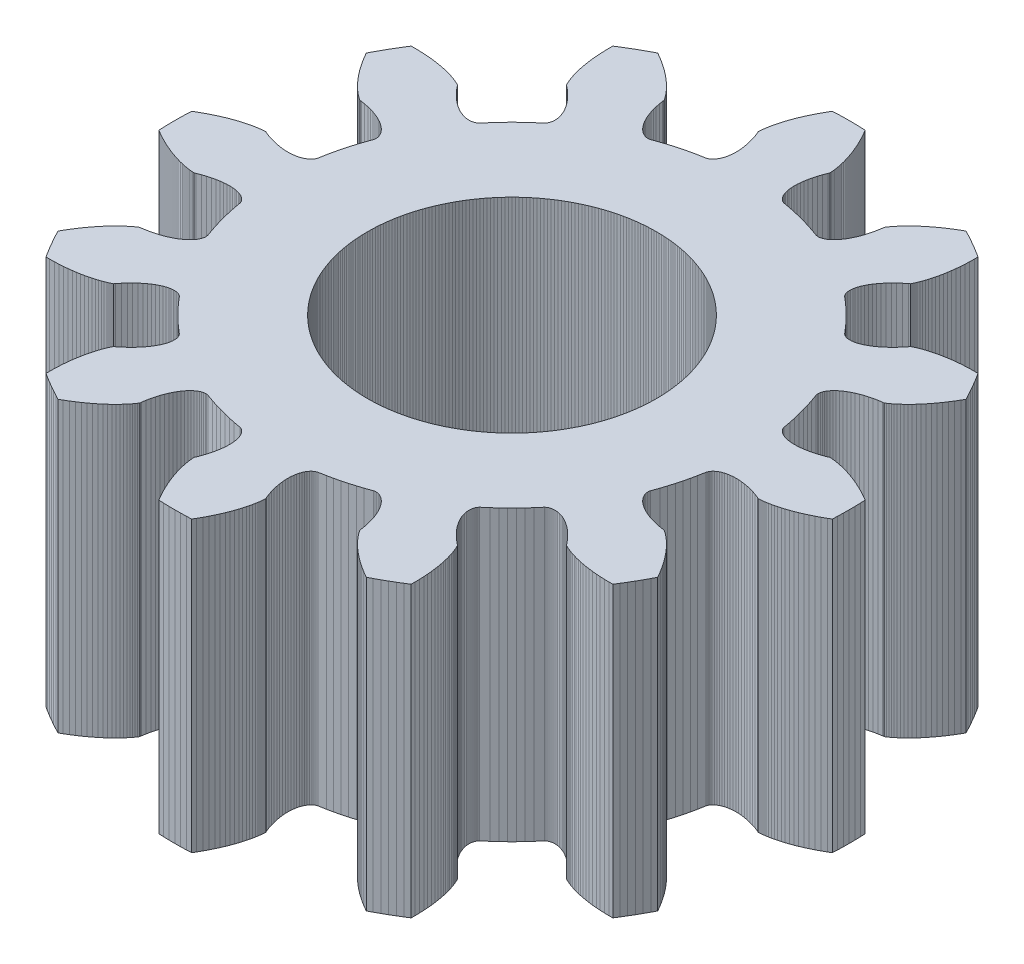
from build123d import *

# Parameters (mm, degrees)
BOSS_EXTRUDE1_DEPTH = 6.35


with BuildPart() as part:
    # Sketch3 → Boss-Extrude1 (new body)
    with BuildSketch(Plane(origin=(0, 0, 0), x_dir=(1, 0, 0), z_dir=(0, 1, 0))):
        Polygon((6.352324032, -3.811995371), (6.415800573, -3.704164188), (6.477446846, -3.5952763), (6.537245267, -3.48536277), (6.588458816, -3.387319635), (6.548537306, -3.316595297), (6.495884299, -3.228769109), (6.443215338, -3.145914469), (6.390753066, -3.06796958), (6.338716813, -2.994864435), (6.287322326, -2.926520952), (6.236781496, -2.862853119), (6.187302087, -2.803767138), (6.139087482, -2.749161584), (6.092336423, -2.698927578), (6.047242762, -2.652948955), (6.003995218, -2.611102449), (5.962777138, -2.573257887), (5.92376627, -2.53927838), (5.887134532, -2.509020536), (5.853047802, -2.482334667), (5.821665703, -2.459065011), (5.793141399, -2.439049957), (5.767621407, -2.422122279), (5.760449484, -2.417630883), (5.727783615, -2.415600485), (5.636581741, -2.400512835), (5.550113125, -2.382418476), (5.468469721, -2.361555299), (5.391734266, -2.338163872), (5.319980198, -2.312487121), (5.253271597, -2.284770003), (5.191663125, -2.255259188), (5.13519999, -2.224202732), (5.083917906, -2.191849747), (5.037843073, -2.158450081), (4.996992084, -2.124254211), (4.961372336, -2.08951179), (4.930981205, -2.054473591), (4.905806921, -2.019388861), (4.885828153, -1.984506202), (4.871014126, -1.950073026), (4.861324716, -1.916335146), (4.856710476, -1.883536522), (4.857112722, -1.851918927), (4.862463612, -1.821721631), (4.91656345, -1.668948402), (4.958566642, -1.539675868), (4.997171481, -1.409348117), (5.032351508, -1.278054469), (5.064082612, -1.145884906), (5.092343047, -1.012930011), (5.121877828, -0.853574595), (5.13234247, -0.824747525), (5.147802912, -0.797164761), (5.168198273, -0.771067439), (5.193458489, -0.746694283), (5.2235044, -0.724281291), (5.258247849, -0.704061425), (5.297591783, -0.686264298), (5.341430376, -0.671115876), (5.389649152, -0.658838167), (5.442125122, -0.649648933), (5.498726931, -0.643761391), (5.559315011, -0.641383926), (5.623741749, -0.642719814), (5.691851657, -0.647966934), (5.76348156, -0.657317507), (5.838460781, -0.670957821), (5.916611348, -0.689067979), (5.997748198, -0.71182164), (6.081679396, -0.739385773), (6.16820636, -0.771920423), (6.197511031, -0.78649498), (6.205967799, -0.786191279), (6.236532595, -0.784291448), (6.271243328, -0.781220033), (6.31005542, -0.776759019), (6.352918329, -0.770691743), (6.399771266, -0.76280355), (6.450545422, -0.752881869), (6.505163607, -0.740716556), (6.563540332, -0.726100191), (6.6255819, -0.708828366), (6.691186508, -0.68869997), (6.760244357, -0.665517476), (6.832637773, -0.639087219), (6.908241333, -0.609219674), (6.986922005, -0.575729725), (7.068539294, -0.538436939), (7.1529454, -0.497165821), (7.239985377, -0.451746078), (7.329497313, -0.402012872), (7.399432523, -0.360724553), (7.404101857, -0.250209934), (7.407271671, -0.125122814), (7.408328376, 0), (7.407271671, 0.125122814), (7.404101857, 0.250209934), (7.399432523, 0.360724553), (7.329497313, 0.402012872), (7.239985377, 0.451746078), (7.1529454, 0.497165821), (7.068539294, 0.538436939), (6.986922005, 0.575729725), (6.908241333, 0.609219674), (6.832637773, 0.639087219), (6.760244357, 0.665517476), (6.691186508, 0.68869997), (6.6255819, 0.708828366), (6.563540332, 0.726100191), (6.505163607, 0.740716556), (6.450545422, 0.752881869), (6.399771266, 0.76280355), (6.352918329, 0.770691743), (6.31005542, 0.776759019), (6.271242896, 0.781220082), (6.236532598, 0.784291476), (6.205967798, 0.786191279), (6.197511031, 0.78649498), (6.16820636, 0.771920423), (6.081679396, 0.739385773), (5.997748198, 0.71182164), (5.916611348, 0.689067979), (5.838460781, 0.670957821), (5.76348156, 0.657317507), (5.691851657, 0.647966934), (5.623741749, 0.642719814), (5.559315011, 0.641383926), (5.498726931, 0.64376139), (5.442125122, 0.649648933), (5.389649193, 0.658837931), (5.341430376, 0.671115876), (5.297591785, 0.686264282), (5.25824785, 0.704061406), (5.2235044, 0.724281291), (5.193458489, 0.746694283), (5.168198273, 0.771067439), (5.147802912, 0.797164761), (5.13234247, 0.824747525), (5.121877828, 0.853574595), (5.092343048, 1.012930011), (5.064082612, 1.145884906), (5.032351508, 1.278054469), (4.997171481, 1.409348117), (4.958566642, 1.539675868), (4.916563449, 1.668948402), (4.862463612, 1.821721631), (4.857112722, 1.851918927), (4.856710476, 1.883536522), (4.861324716, 1.916335146), (4.871014126, 1.950073026), (4.885828153, 1.984506202), (4.905806929, 2.019388845), (4.930981212, 2.054473575), (4.961372336, 2.08951179), (4.996992167, 2.124253986), (5.037843073, 2.158450081), (5.083917906, 2.191849747), (5.13519999, 2.224202732), (5.191663125, 2.255259188), (5.253271597, 2.284770003), (5.319980198, 2.312487121), (5.391734266, 2.338163872), (5.468469721, 2.361555299), (5.550113125, 2.382418476), (5.636581741, 2.400512835), (5.727783615, 2.415600485), (5.760449483, 2.417630883), (5.767621408, 2.42212228), (5.793141383, 2.43904998), (5.821666052, 2.45906527), (5.853047802, 2.482334667), (5.887134532, 2.509020536), (5.92376627, 2.53927838), (5.962777138, 2.573257887), (6.003995218, 2.611102449), (6.047242762, 2.652948955), (6.092336423, 2.698927578), (6.139087482, 2.749161584), (6.187302087, 2.803767138), (6.236781496, 2.862853119), (6.287322326, 2.926520952), (6.338716813, 2.994864435), (6.390753066, 3.06796958), (6.443215338, 3.145914469), (6.495884299, 3.228769109), (6.548537306, 3.316595297), (6.588458816, 3.387319635), (6.537245267, 3.48536277), (6.477446846, 3.5952763), (6.415800573, 3.704164188), (6.352324032, 3.811995371), (6.287035334, 3.918739087), (6.227734262, 4.012112889), (6.146524434, 4.012902016), (6.044138221, 4.011216269), (5.946049518, 4.00703093), (5.852316127, 4.000569714), (5.762987088, 3.99205757), (5.678102653, 3.98172038), (5.597694277, 3.969784654), (5.521784611, 3.95647722), (5.450387512, 3.942024924), (5.383508057, 3.926654322), (5.321142571, 3.910591377), (5.263278662, 3.894061158), (5.20989527, 3.877287535), (5.160962719, 3.860492886), (5.116442789, 3.843897793), (5.076288783, 3.827720753), (5.04044562, 3.812177885), (5.008849923, 3.797482641), (4.981430128, 3.783845519), (4.973954503, 3.779880148), (4.955863193, 3.752605876), (4.897195968, 3.681166561), (4.838291485, 3.615329722), (4.779401742, 3.555056049), (4.720776444, 3.500296909), (4.662662691, 3.450994439), (4.605304663, 3.407081654), (4.548943312, 3.36848256), (4.493816064, 3.335112279), (4.440156515, 3.306877183), (4.38819414, 3.283675041), (4.338154153, 3.265394982), (4.29025646, 3.251918585), (4.244716924, 3.243118194), (4.201745515, 3.238858989), (4.161546862, 3.238998198), (4.124319843, 3.243385462), (4.090257276, 3.251863127), (4.059545715, 3.26426639), (4.032365197, 3.280423543), (4.008889017, 3.300156197), (3.903633438, 3.423394646), (3.812681736, 3.524406745), (3.719117012, 3.623003391), (3.623003391, 3.719117012), (3.524406745, 3.812681736), (3.423394645, 3.903633438), (3.300156197, 4.008889017), (3.280423543, 4.032365197), (3.26426639, 4.059545715), (3.251863127, 4.090257276), (3.243385462, 4.124319843), (3.238998198, 4.161546862), (3.238859004, 4.201745504), (3.243118208, 4.244716913), (3.251918585, 4.29025646), (3.265395166, 4.338153999), (3.283675041, 4.38819414), (3.306877184, 4.440156515), (3.335112279, 4.493816064), (3.36848256, 4.548943312), (3.407081654, 4.605304663), (3.450994439, 4.662662691), (3.500296909, 4.720776444), (3.555056049, 4.779401742), (3.615329722, 4.838291485), (3.681166561, 4.897195968), (3.752605876, 4.955863193), (3.779880148, 4.973954503), (3.783845519, 4.981430129), (3.797482616, 5.008849935), (3.812178058, 5.040446019), (3.827720753, 5.076288783), (3.843897793, 5.116442789), (3.860492886, 5.160962719), (3.877287535, 5.20989527), (3.894061158, 5.263278662), (3.910591377, 5.321142571), (3.926654322, 5.383508057), (3.942024924, 5.450387512), (3.95647722, 5.521784611), (3.969784654, 5.597694277), (3.98172038, 5.678102653), (3.99205757, 5.762987088), (4.000569714, 5.852316127), (4.00703093, 5.946049518), (4.011216269, 6.044138221), (4.012902016, 6.146524434), (4.012112889, 6.227734262), (3.918739087, 6.287035334), (3.811995371, 6.352324032), (3.704164188, 6.415800573), (3.5952763, 6.477446846), (3.48536277, 6.537245267), (3.387319635, 6.588458816), (3.316595297, 6.548537306), (3.228769109, 6.495884299), (3.145914469, 6.443215338), (3.06796958, 6.390753066), (2.994864435, 6.338716813), (2.926520952, 6.287322326), (2.862853119, 6.236781496), (2.803767138, 6.187302087), (2.749161584, 6.139087482), (2.698927578, 6.092336423), (2.652948955, 6.047242762), (2.611102449, 6.003995218), (2.573257887, 5.962777138), (2.53927838, 5.92376627), (2.509020536, 5.887134532), (2.482334667, 5.853047802), (2.459065011, 5.821665703), (2.439049957, 5.793141399), (2.422122279, 5.767621407), (2.417630883, 5.760449484), (2.415600485, 5.727783615), (2.400512835, 5.636581741), (2.382418476, 5.550113125), (2.361555299, 5.468469721), (2.338163872, 5.391734266), (2.312487121, 5.319980198), (2.284770003, 5.253271597), (2.255259188, 5.191663125), (2.224202732, 5.13519999), (2.191849747, 5.083917906), (2.158450081, 5.037843073), (2.124254211, 4.996992084), (2.08951179, 4.961372336), (2.054473591, 4.930981205), (2.019388861, 4.905806921), (1.984506202, 4.885828153), (1.950073026, 4.871014126), (1.916335146, 4.861324716), (1.883536522, 4.856710476), (1.851918927, 4.857112722), (1.821721631, 4.862463612), (1.668948402, 4.91656345), (1.539675868, 4.958566642), (1.409348117, 4.997171481), (1.278054469, 5.032351508), (1.145884906, 5.064082612), (1.012930011, 5.092343047), (0.853574595, 5.121877828), (0.824747525, 5.13234247), (0.797164761, 5.147802912), (0.771067439, 5.168198273), (0.746694283, 5.193458489), (0.724281291, 5.2235044), (0.704061425, 5.258247849), (0.686264298, 5.297591783), (0.671115876, 5.341430376), (0.658838167, 5.389649152), (0.649648933, 5.442125122), (0.643761391, 5.498726931), (0.641383926, 5.559315011), (0.642719814, 5.623741749), (0.647966934, 5.691851657), (0.657317507, 5.76348156), (0.670957821, 5.838460781), (0.689067979, 5.916611348), (0.71182164, 5.997748198), (0.739385773, 6.081679396), (0.771920423, 6.16820636), (0.78649498, 6.197511031), (0.786191279, 6.205967799), (0.784291448, 6.236532595), (0.781220033, 6.271243328), (0.776759019, 6.31005542), (0.770691743, 6.352918329), (0.76280355, 6.399771266), (0.752881869, 6.450545422), (0.740716556, 6.505163607), (0.726100191, 6.563540332), (0.708828366, 6.6255819), (0.68869997, 6.691186508), (0.665517476, 6.760244357), (0.639087219, 6.832637773), (0.609219674, 6.908241333), (0.575729725, 6.986922005), (0.538436939, 7.068539294), (0.497165821, 7.1529454), (0.451746078, 7.239985377), (0.402012872, 7.329497313), (0.360724553, 7.399432523), (0.250209934, 7.404101857), (0.125122814, 7.407271671), (0, 7.408328376), (-0.125122814, 7.407271671), (-0.250209934, 7.404101857), (-0.360724553, 7.399432523), (-0.402012872, 7.329497313), (-0.451746078, 7.239985377), (-0.497165821, 7.1529454), (-0.538436939, 7.068539294), (-0.575729725, 6.986922005), (-0.609219674, 6.908241333), (-0.639087219, 6.832637773), (-0.665517476, 6.760244357), (-0.68869997, 6.691186508), (-0.708828366, 6.6255819), (-0.726100191, 6.563540332), (-0.740716556, 6.505163607), (-0.752881869, 6.450545422), (-0.76280355, 6.399771266), (-0.770691743, 6.352918329), (-0.776759019, 6.31005542), (-0.781220082, 6.271242896), (-0.784291476, 6.236532598), (-0.786191279, 6.205967798), (-0.78649498, 6.197511031), (-0.771920423, 6.16820636), (-0.739385773, 6.081679396), (-0.71182164, 5.997748198), (-0.689067979, 5.916611348), (-0.670957821, 5.838460781), (-0.657317507, 5.76348156), (-0.647966934, 5.691851657), (-0.642719814, 5.623741749), (-0.641383926, 5.559315011), (-0.64376139, 5.498726931), (-0.649648933, 5.442125122), (-0.658837931, 5.389649193), (-0.671115876, 5.341430376), (-0.686264282, 5.297591785), (-0.704061406, 5.25824785), (-0.724281291, 5.2235044), (-0.746694283, 5.193458489), (-0.771067439, 5.168198273), (-0.797164761, 5.147802912), (-0.824747525, 5.13234247), (-0.853574595, 5.121877828), (-1.012930011, 5.092343048), (-1.145884906, 5.064082612), (-1.278054469, 5.032351508), (-1.409348117, 4.997171481), (-1.539675868, 4.958566642), (-1.668948402, 4.916563449), (-1.821721631, 4.862463612), (-1.851918927, 4.857112722), (-1.883536522, 4.856710476), (-1.916335146, 4.861324716), (-1.950073026, 4.871014126), (-1.984506202, 4.885828153), (-2.019388845, 4.905806929), (-2.054473575, 4.930981212), (-2.08951179, 4.961372336), (-2.124253986, 4.996992167), (-2.158450081, 5.037843073), (-2.191849747, 5.083917906), (-2.224202732, 5.13519999), (-2.255259188, 5.191663125), (-2.284770003, 5.253271597), (-2.312487121, 5.319980198), (-2.338163872, 5.391734266), (-2.361555299, 5.468469721), (-2.382418476, 5.550113125), (-2.400512835, 5.636581741), (-2.415600485, 5.727783615), (-2.417630883, 5.760449483), (-2.42212228, 5.767621408), (-2.43904998, 5.793141383), (-2.45906527, 5.821666052), (-2.482334667, 5.853047802), (-2.509020536, 5.887134532), (-2.53927838, 5.92376627), (-2.573257887, 5.962777138), (-2.611102449, 6.003995218), (-2.652948955, 6.047242762), (-2.698927578, 6.092336423), (-2.749161584, 6.139087482), (-2.803767138, 6.187302087), (-2.862853119, 6.236781496), (-2.926520952, 6.287322326), (-2.994864435, 6.338716813), (-3.06796958, 6.390753066), (-3.145914469, 6.443215338), (-3.228769109, 6.495884299), (-3.316595297, 6.548537306), (-3.387319635, 6.588458816), (-3.48536277, 6.537245267), (-3.5952763, 6.477446846), (-3.704164188, 6.415800573), (-3.811995371, 6.352324032), (-3.918739087, 6.287035334), (-4.012112889, 6.227734262), (-4.012902016, 6.146524434), (-4.011216269, 6.044138221), (-4.00703093, 5.946049518), (-4.000569714, 5.852316127), (-3.99205757, 5.762987088), (-3.98172038, 5.678102653), (-3.969784654, 5.597694277), (-3.95647722, 5.521784611), (-3.942024924, 5.450387512), (-3.926654322, 5.383508057), (-3.910591377, 5.321142571), (-3.894061158, 5.263278662), (-3.877287535, 5.20989527), (-3.860492886, 5.160962719), (-3.843897793, 5.116442789), (-3.827720753, 5.076288783), (-3.812177885, 5.04044562), (-3.797482641, 5.008849923), (-3.783845519, 4.981430128), (-3.779880148, 4.973954503), (-3.752605876, 4.955863193), (-3.681166561, 4.897195968), (-3.615329722, 4.838291485), (-3.555056049, 4.779401742), (-3.500296909, 4.720776444), (-3.450994439, 4.662662691), (-3.407081654, 4.605304663), (-3.36848256, 4.548943312), (-3.335112279, 4.493816064), (-3.306877183, 4.440156515), (-3.283675041, 4.38819414), (-3.265394982, 4.338154153), (-3.251918585, 4.29025646), (-3.243118194, 4.244716924), (-3.238858989, 4.201745515), (-3.238998198, 4.161546862), (-3.243385462, 4.124319843), (-3.251863127, 4.090257276), (-3.26426639, 4.059545715), (-3.280423543, 4.032365197), (-3.300156197, 4.008889017), (-3.423394646, 3.903633438), (-3.524406745, 3.812681736), (-3.623003391, 3.719117012), (-3.719117012, 3.623003391), (-3.812681736, 3.524406745), (-3.903633438, 3.423394645), (-4.008889017, 3.300156197), (-4.032365197, 3.280423543), (-4.059545715, 3.26426639), (-4.090257276, 3.251863127), (-4.124319843, 3.243385462), (-4.161546862, 3.238998198), (-4.201745504, 3.238859004), (-4.244716913, 3.243118208), (-4.29025646, 3.251918585), (-4.338153999, 3.265395166), (-4.38819414, 3.283675041), (-4.440156515, 3.306877184), (-4.493816064, 3.335112279), (-4.548943312, 3.36848256), (-4.605304663, 3.407081654), (-4.662662691, 3.450994439), (-4.720776444, 3.500296909), (-4.779401742, 3.555056049), (-4.838291485, 3.615329722), (-4.897195968, 3.681166561), (-4.955863193, 3.752605876), (-4.973954503, 3.779880148), (-4.981430129, 3.783845519), (-5.008849935, 3.797482616), (-5.040446019, 3.812178058), (-5.076288783, 3.827720753), (-5.116442789, 3.843897793), (-5.160962719, 3.860492886), (-5.20989527, 3.877287535), (-5.263278662, 3.894061158), (-5.321142571, 3.910591377), (-5.383508057, 3.926654322), (-5.450387512, 3.942024924), (-5.521784611, 3.95647722), (-5.597694277, 3.969784654), (-5.678102653, 3.98172038), (-5.762987088, 3.99205757), (-5.852316127, 4.000569714), (-5.946049518, 4.00703093), (-6.044138221, 4.011216269), (-6.146524434, 4.012902016), (-6.227734262, 4.012112889), (-6.287035334, 3.918739087), (-6.352324032, 3.811995371), (-6.415800573, 3.704164188), (-6.477446846, 3.5952763), (-6.537245267, 3.48536277), (-6.588458816, 3.387319635), (-6.548537306, 3.316595297), (-6.495884299, 3.228769109), (-6.443215338, 3.145914469), (-6.390753066, 3.06796958), (-6.338716813, 2.994864435), (-6.287322326, 2.926520952), (-6.236781496, 2.862853119), (-6.187302087, 2.803767138), (-6.139087482, 2.749161584), (-6.092336423, 2.698927578), (-6.047242762, 2.652948955), (-6.003995218, 2.611102449), (-5.962777138, 2.573257887), (-5.92376627, 2.53927838), (-5.887134532, 2.509020536), (-5.853047802, 2.482334667), (-5.821665703, 2.459065011), (-5.793141399, 2.439049957), (-5.767621407, 2.422122279), (-5.760449484, 2.417630883), (-5.727783615, 2.415600485), (-5.636581741, 2.400512835), (-5.550113125, 2.382418476), (-5.468469721, 2.361555299), (-5.391734266, 2.338163872), (-5.319980198, 2.312487121), (-5.253271597, 2.284770003), (-5.191663125, 2.255259188), (-5.13519999, 2.224202732), (-5.083917906, 2.191849747), (-5.037843073, 2.158450081), (-4.996992084, 2.124254211), (-4.961372336, 2.08951179), (-4.930981205, 2.054473591), (-4.905806921, 2.019388861), (-4.885828153, 1.984506202), (-4.871014126, 1.950073026), (-4.861324716, 1.916335146), (-4.856710476, 1.883536522), (-4.857112722, 1.851918927), (-4.862463612, 1.821721631), (-4.91656345, 1.668948402), (-4.958566642, 1.539675868), (-4.997171481, 1.409348117), (-5.032351508, 1.278054469), (-5.064082612, 1.145884906), (-5.092343047, 1.012930011), (-5.121877828, 0.853574595), (-5.13234247, 0.824747525), (-5.147802912, 0.797164761), (-5.168198273, 0.771067439), (-5.193458489, 0.746694283), (-5.2235044, 0.724281291), (-5.258247849, 0.704061425), (-5.297591783, 0.686264298), (-5.341430376, 0.671115876), (-5.389649152, 0.658838167), (-5.442125122, 0.649648933), (-5.498726931, 0.643761391), (-5.559315011, 0.641383926), (-5.623741749, 0.642719814), (-5.691851657, 0.647966934), (-5.76348156, 0.657317507), (-5.838460781, 0.670957821), (-5.916611348, 0.689067979), (-5.997748198, 0.71182164), (-6.081679396, 0.739385773), (-6.16820636, 0.771920423), (-6.197511031, 0.78649498), (-6.205967799, 0.786191279), (-6.236532595, 0.784291448), (-6.271243328, 0.781220033), (-6.31005542, 0.776759019), (-6.352918329, 0.770691743), (-6.399771266, 0.76280355), (-6.450545422, 0.752881869), (-6.505163607, 0.740716556), (-6.563540332, 0.726100191), (-6.6255819, 0.708828366), (-6.691186508, 0.68869997), (-6.760244357, 0.665517476), (-6.832637773, 0.639087219), (-6.908241333, 0.609219674), (-6.986922005, 0.575729725), (-7.068539294, 0.538436939), (-7.1529454, 0.497165821), (-7.239985377, 0.451746078), (-7.329497313, 0.402012872), (-7.399432523, 0.360724553), (-7.404101857, 0.250209934), (-7.407271671, 0.125122814), (-7.408328376, 0), (-7.407271671, -0.125122814), (-7.404101857, -0.250209934), (-7.399432523, -0.360724553), (-7.329497313, -0.402012872), (-7.239985377, -0.451746078), (-7.1529454, -0.497165821), (-7.068539294, -0.538436939), (-6.986922005, -0.575729725), (-6.908241333, -0.609219674), (-6.832637773, -0.639087219), (-6.760244357, -0.665517476), (-6.691186508, -0.68869997), (-6.6255819, -0.708828366), (-6.563540332, -0.726100191), (-6.505163607, -0.740716556), (-6.450545422, -0.752881869), (-6.399771266, -0.76280355), (-6.352918329, -0.770691743), (-6.31005542, -0.776759019), (-6.271242896, -0.781220082), (-6.236532598, -0.784291476), (-6.205967798, -0.786191279), (-6.197511031, -0.78649498), (-6.16820636, -0.771920423), (-6.081679396, -0.739385773), (-5.997748198, -0.71182164), (-5.916611348, -0.689067979), (-5.838460781, -0.670957821), (-5.76348156, -0.657317507), (-5.691851657, -0.647966934), (-5.623741749, -0.642719814), (-5.559315011, -0.641383926), (-5.498726931, -0.64376139), (-5.442125122, -0.649648933), (-5.389649193, -0.658837931), (-5.341430376, -0.671115876), (-5.297591785, -0.686264282), (-5.25824785, -0.704061406), (-5.2235044, -0.724281291), (-5.193458489, -0.746694283), (-5.168198273, -0.771067439), (-5.147802912, -0.797164761), (-5.13234247, -0.824747525), (-5.121877828, -0.853574595), (-5.092343048, -1.012930011), (-5.064082612, -1.145884906), (-5.032351508, -1.278054469), (-4.997171481, -1.409348117), (-4.958566642, -1.539675868), (-4.916563449, -1.668948402), (-4.862463612, -1.821721631), (-4.857112722, -1.851918927), (-4.856710476, -1.883536522), (-4.861324716, -1.916335146), (-4.871014126, -1.950073026), (-4.885828153, -1.984506202), (-4.905806929, -2.019388845), (-4.930981212, -2.054473575), (-4.961372336, -2.08951179), (-4.996992167, -2.124253986), (-5.037843073, -2.158450081), (-5.083917906, -2.191849747), (-5.13519999, -2.224202732), (-5.191663125, -2.255259188), (-5.253271597, -2.284770003), (-5.319980198, -2.312487121), (-5.391734266, -2.338163872), (-5.468469721, -2.361555299), (-5.550113125, -2.382418476), (-5.636581741, -2.400512835), (-5.727783615, -2.415600485), (-5.760449483, -2.417630883), (-5.767621408, -2.42212228), (-5.793141383, -2.43904998), (-5.821666052, -2.45906527), (-5.853047802, -2.482334667), (-5.887134532, -2.509020536), (-5.92376627, -2.53927838), (-5.962777138, -2.573257887), (-6.003995218, -2.611102449), (-6.047242762, -2.652948955), (-6.092336423, -2.698927578), (-6.139087482, -2.749161584), (-6.187302087, -2.803767138), (-6.236781496, -2.862853119), (-6.287322326, -2.926520952), (-6.338716813, -2.994864435), (-6.390753066, -3.06796958), (-6.443215338, -3.145914469), (-6.495884299, -3.228769109), (-6.548537306, -3.316595297), (-6.588458816, -3.387319635), (-6.537245267, -3.48536277), (-6.477446846, -3.5952763), (-6.415800573, -3.704164188), (-6.352324032, -3.811995371), (-6.287035334, -3.918739087), (-6.227734262, -4.012112889), (-6.146524434, -4.012902016), (-6.044138221, -4.011216269), (-5.946049518, -4.00703093), (-5.852316127, -4.000569714), (-5.762987088, -3.99205757), (-5.678102653, -3.98172038), (-5.597694277, -3.969784654), (-5.521784611, -3.95647722), (-5.450387512, -3.942024924), (-5.383508057, -3.926654322), (-5.321142571, -3.910591377), (-5.263278662, -3.894061158), (-5.20989527, -3.877287535), (-5.160962719, -3.860492886), (-5.116442789, -3.843897793), (-5.076288783, -3.827720753), (-5.04044562, -3.812177885), (-5.008849923, -3.797482641), (-4.981430128, -3.783845519), (-4.973954503, -3.779880148), (-4.955863193, -3.752605876), (-4.897195968, -3.681166561), (-4.838291485, -3.615329722), (-4.779401742, -3.555056049), (-4.720776444, -3.500296909), (-4.662662691, -3.450994439), (-4.605304663, -3.407081654), (-4.548943312, -3.36848256), (-4.493816064, -3.335112279), (-4.440156515, -3.306877183), (-4.38819414, -3.283675041), (-4.338154153, -3.265394982), (-4.29025646, -3.251918585), (-4.244716924, -3.243118194), (-4.201745515, -3.238858989), (-4.161546862, -3.238998198), (-4.124319843, -3.243385462), (-4.090257276, -3.251863127), (-4.059545715, -3.26426639), (-4.032365197, -3.280423543), (-4.008889017, -3.300156197), (-3.903633438, -3.423394646), (-3.812681736, -3.524406745), (-3.719117012, -3.623003391), (-3.623003391, -3.719117012), (-3.524406745, -3.812681736), (-3.423394645, -3.903633438), (-3.300156197, -4.008889017), (-3.280423543, -4.032365197), (-3.26426639, -4.059545715), (-3.251863127, -4.090257276), (-3.243385462, -4.124319843), (-3.238998198, -4.161546862), (-3.238859004, -4.201745504), (-3.243118208, -4.244716913), (-3.251918585, -4.29025646), (-3.265395166, -4.338153999), (-3.283675041, -4.38819414), (-3.306877184, -4.440156515), (-3.335112279, -4.493816064), (-3.36848256, -4.548943312), (-3.407081654, -4.605304663), (-3.450994439, -4.662662691), (-3.500296909, -4.720776444), (-3.555056049, -4.779401742), (-3.615329722, -4.838291485), (-3.681166561, -4.897195968), (-3.752605876, -4.955863193), (-3.779880148, -4.973954503), (-3.783845519, -4.981430129), (-3.797482616, -5.008849935), (-3.812178058, -5.040446019), (-3.827720753, -5.076288783), (-3.843897793, -5.116442789), (-3.860492886, -5.160962719), (-3.877287535, -5.20989527), (-3.894061158, -5.263278662), (-3.910591377, -5.321142571), (-3.926654322, -5.383508057), (-3.942024924, -5.450387512), (-3.95647722, -5.521784611), (-3.969784654, -5.597694277), (-3.98172038, -5.678102653), (-3.99205757, -5.762987088), (-4.000569714, -5.852316127), (-4.00703093, -5.946049518), (-4.011216269, -6.044138221), (-4.012902016, -6.146524434), (-4.012112889, -6.227734262), (-3.918739087, -6.287035334), (-3.811995371, -6.352324032), (-3.704164188, -6.415800573), (-3.5952763, -6.477446846), (-3.48536277, -6.537245267), (-3.387319635, -6.588458816), (-3.316595297, -6.548537306), (-3.228769109, -6.495884299), (-3.145914469, -6.443215338), (-3.06796958, -6.390753066), (-2.994864435, -6.338716813), (-2.926520952, -6.287322326), (-2.862853119, -6.236781496), (-2.803767138, -6.187302087), (-2.749161584, -6.139087482), (-2.698927578, -6.092336423), (-2.652948955, -6.047242762), (-2.611102449, -6.003995218), (-2.573257887, -5.962777138), (-2.53927838, -5.92376627), (-2.509020536, -5.887134532), (-2.482334667, -5.853047802), (-2.459065011, -5.821665703), (-2.439049957, -5.793141399), (-2.422122279, -5.767621407), (-2.417630883, -5.760449484), (-2.415600485, -5.727783615), (-2.400512835, -5.636581741), (-2.382418476, -5.550113125), (-2.361555299, -5.468469721), (-2.338163872, -5.391734266), (-2.312487121, -5.319980198), (-2.284770003, -5.253271597), (-2.255259188, -5.191663125), (-2.224202732, -5.13519999), (-2.191849747, -5.083917906), (-2.158450081, -5.037843073), (-2.124254211, -4.996992084), (-2.08951179, -4.961372336), (-2.054473591, -4.930981205), (-2.019388861, -4.905806921), (-1.984506202, -4.885828153), (-1.950073026, -4.871014126), (-1.916335146, -4.861324716), (-1.883536522, -4.856710476), (-1.851918927, -4.857112722), (-1.821721631, -4.862463612), (-1.668948402, -4.91656345), (-1.539675868, -4.958566642), (-1.409348117, -4.997171481), (-1.278054469, -5.032351508), (-1.145884906, -5.064082612), (-1.012930011, -5.092343047), (-0.853574595, -5.121877828), (-0.824747525, -5.13234247), (-0.797164761, -5.147802912), (-0.771067439, -5.168198273), (-0.746694283, -5.193458489), (-0.724281291, -5.2235044), (-0.704061425, -5.258247849), (-0.686264298, -5.297591783), (-0.671115876, -5.341430376), (-0.658838167, -5.389649152), (-0.649648933, -5.442125122), (-0.643761391, -5.498726931), (-0.641383926, -5.559315011), (-0.642719814, -5.623741749), (-0.647966934, -5.691851657), (-0.657317507, -5.76348156), (-0.670957821, -5.838460781), (-0.689067979, -5.916611348), (-0.71182164, -5.997748198), (-0.739385773, -6.081679396), (-0.771920423, -6.16820636), (-0.78649498, -6.197511031), (-0.786191279, -6.205967799), (-0.784291448, -6.236532595), (-0.781220033, -6.271243328), (-0.776759019, -6.31005542), (-0.770691743, -6.352918329), (-0.76280355, -6.399771266), (-0.752881869, -6.450545422), (-0.740716556, -6.505163607), (-0.726100191, -6.563540332), (-0.708828366, -6.6255819), (-0.68869997, -6.691186508), (-0.665517476, -6.760244357), (-0.639087219, -6.832637773), (-0.609219674, -6.908241333), (-0.575729725, -6.986922005), (-0.538436939, -7.068539294), (-0.497165821, -7.1529454), (-0.451746078, -7.239985377), (-0.402012872, -7.329497313), (-0.360724553, -7.399432523), (-0.250209934, -7.404101857), (-0.125122814, -7.407271671), (0, -7.408328376), (0.125122814, -7.407271671), (0.250209934, -7.404101857), (0.360724553, -7.399432523), (0.402012872, -7.329497313), (0.451746078, -7.239985377), (0.497165821, -7.1529454), (0.538436939, -7.068539294), (0.575729725, -6.986922005), (0.609219674, -6.908241333), (0.639087219, -6.832637773), (0.665517476, -6.760244357), (0.68869997, -6.691186508), (0.708828366, -6.6255819), (0.726100191, -6.563540332), (0.740716556, -6.505163607), (0.752881869, -6.450545422), (0.76280355, -6.399771266), (0.770691743, -6.352918329), (0.776759019, -6.31005542), (0.781220082, -6.271242896), (0.784291476, -6.236532598), (0.786191279, -6.205967798), (0.78649498, -6.197511031), (0.771920423, -6.16820636), (0.739385773, -6.081679396), (0.71182164, -5.997748198), (0.689067979, -5.916611348), (0.670957821, -5.838460781), (0.657317507, -5.76348156), (0.647966934, -5.691851657), (0.642719814, -5.623741749), (0.641383926, -5.559315011), (0.64376139, -5.498726931), (0.649648933, -5.442125122), (0.658837931, -5.389649193), (0.671115876, -5.341430376), (0.686264282, -5.297591785), (0.704061406, -5.25824785), (0.724281291, -5.2235044), (0.746694283, -5.193458489), (0.771067439, -5.168198273), (0.797164761, -5.147802912), (0.824747525, -5.13234247), (0.853574595, -5.121877828), (1.012930011, -5.092343048), (1.145884906, -5.064082612), (1.278054469, -5.032351508), (1.409348117, -4.997171481), (1.539675868, -4.958566642), (1.668948402, -4.916563449), (1.821721631, -4.862463612), (1.851918927, -4.857112722), (1.883536522, -4.856710476), (1.916335146, -4.861324716), (1.950073026, -4.871014126), (1.984506202, -4.885828153), (2.019388845, -4.905806929), (2.054473575, -4.930981212), (2.08951179, -4.961372336), (2.124253986, -4.996992167), (2.158450081, -5.037843073), (2.191849747, -5.083917906), (2.224202732, -5.13519999), (2.255259188, -5.191663125), (2.284770003, -5.253271597), (2.312487121, -5.319980198), (2.338163872, -5.391734266), (2.361555299, -5.468469721), (2.382418476, -5.550113125), (2.400512835, -5.636581741), (2.415600485, -5.727783615), (2.417630883, -5.760449483), (2.42212228, -5.767621408), (2.43904998, -5.793141383), (2.45906527, -5.821666052), (2.482334667, -5.853047802), (2.509020536, -5.887134532), (2.53927838, -5.92376627), (2.573257887, -5.962777138), (2.611102449, -6.003995218), (2.652948955, -6.047242762), (2.698927578, -6.092336423), (2.749161584, -6.139087482), (2.803767138, -6.187302087), (2.862853119, -6.236781496), (2.926520952, -6.287322326), (2.994864435, -6.338716813), (3.06796958, -6.390753066), (3.145914469, -6.443215338), (3.228769109, -6.495884299), (3.316595297, -6.548537306), (3.387319635, -6.588458816), (3.48536277, -6.537245267), (3.5952763, -6.477446846), (3.704164188, -6.415800573), (3.811995371, -6.352324032), (3.918739087, -6.287035334), (4.012112889, -6.227734262), (4.012902016, -6.146524434), (4.011216269, -6.044138221), (4.00703093, -5.946049518), (4.000569714, -5.852316127), (3.99205757, -5.762987088), (3.98172038, -5.678102653), (3.969784654, -5.597694277), (3.95647722, -5.521784611), (3.942024924, -5.450387512), (3.926654322, -5.383508057), (3.910591377, -5.321142571), (3.894061158, -5.263278662), (3.877287535, -5.20989527), (3.860492886, -5.160962719), (3.843897793, -5.116442789), (3.827720753, -5.076288783), (3.812177885, -5.04044562), (3.797482641, -5.008849923), (3.783845519, -4.981430128), (3.779880148, -4.973954503), (3.752605876, -4.955863193), (3.681166561, -4.897195968), (3.615329722, -4.838291485), (3.555056049, -4.779401742), (3.500296909, -4.720776444), (3.450994439, -4.662662691), (3.407081654, -4.605304663), (3.36848256, -4.548943312), (3.335112279, -4.493816064), (3.306877183, -4.440156515), (3.283675041, -4.38819414), (3.265394982, -4.338154153), (3.251918585, -4.29025646), (3.243118194, -4.244716924), (3.238858989, -4.201745515), (3.238998198, -4.161546862), (3.243385462, -4.124319843), (3.251863127, -4.090257276), (3.26426639, -4.059545715), (3.280423543, -4.032365197), (3.300156197, -4.008889017), (3.423394646, -3.903633438), (3.524406745, -3.812681736), (3.623003391, -3.719117012), (3.719117012, -3.623003391), (3.812681736, -3.524406745), (3.903633438, -3.423394645), (4.008889017, -3.300156197), (4.032365197, -3.280423543), (4.059545715, -3.26426639), (4.090257276, -3.251863127), (4.124319843, -3.243385462), (4.161546862, -3.238998198), (4.201745504, -3.238859004), (4.244716913, -3.243118208), (4.29025646, -3.251918585), (4.338153999, -3.265395166), (4.38819414, -3.283675041), (4.440156515, -3.306877184), (4.493816064, -3.335112279), (4.548943312, -3.36848256), (4.605304663, -3.407081654), (4.662662691, -3.450994439), (4.720776444, -3.500296909), (4.779401742, -3.555056049), (4.838291485, -3.615329722), (4.897195968, -3.681166561), (4.955863193, -3.752605876), (4.973954503, -3.779880148), (4.981430129, -3.783845519), (5.008849935, -3.797482616), (5.040446019, -3.812178058), (5.076288783, -3.827720753), (5.116442789, -3.843897793), (5.160962719, -3.860492886), (5.20989527, -3.877287535), (5.263278662, -3.894061158), (5.321142571, -3.910591377), (5.383508057, -3.926654322), (5.450387512, -3.942024924), (5.521784611, -3.95647722), (5.597694277, -3.969784654), (5.678102653, -3.98172038), (5.762987088, -3.99205757), (5.852316127, -4.000569714), (5.946049518, -4.00703093), (6.044138221, -4.011216269), (6.146524434, -4.012902016), (6.227734262, -4.012112889), (6.287035334, -3.918739087), align=None)
        Polygon((0.05541139, -3.174516432), (0, -3.175), (-0.05541139, -3.174516432), (-0.110805902, -3.173065876), (-0.166166661, -3.170648773), (-0.221476804, -3.16726586), (-0.276719483, -3.162918166), (-0.331877871, -3.157607018), (-0.386935165, -3.151334031), (-0.441874596, -3.144101118), (-0.496679427, -3.135910481), (-0.551332964, -3.126764616), (-0.60581856, -3.116666307), (-0.660119618, -3.105618632), (-0.714219598, -3.093624956), (-0.768102019, -3.080688931), (-0.821750468, -3.066814498), (-0.875148605, -3.052005885), (-0.928280162, -3.0362676), (-0.981128957, -3.019604439), (-1.03367889, -3.002021478), (-1.085913955, -2.983524071), (-1.13781824, -2.964117854), (-1.189375934, -2.943808738), (-1.240571333, -2.92260291), (-1.291388842, -2.900506828), (-1.341812981, -2.877527224), (-1.391828391, -2.853671097), (-1.441419837, -2.828945714), (-1.490572212, -2.803358607), (-1.539270544, -2.77691757), (-1.5875, -2.749630657), (-1.635245888, -2.72150618), (-1.682493664, -2.692552705), (-1.729228936, -2.662779053), (-1.775437469, -2.632194293), (-1.821105185, -2.600807741), (-1.866218176, -2.568628957), (-1.910762699, -2.535667744), (-1.954725184, -2.501934143), (-1.998092242, -2.467438428), (-2.040850661, -2.432191107), (-2.082987417, -2.396202917), (-2.124489675, -2.359484821), (-2.165344793, -2.322048003), (-2.205540326, -2.283903866), (-2.24506403, -2.24506403), (-2.283903866, -2.205540326), (-2.322048003, -2.165344793), (-2.359484821, -2.124489675), (-2.396202917, -2.082987417), (-2.432191107, -2.040850661), (-2.467438428, -1.998092242), (-2.501934143, -1.954725184), (-2.535667744, -1.910762699), (-2.568628957, -1.866218176), (-2.600807741, -1.821105185), (-2.632194293, -1.775437469), (-2.662779053, -1.729228936), (-2.692552705, -1.682493664), (-2.72150618, -1.635245888), (-2.749630657, -1.5875), (-2.77691757, -1.539270544), (-2.803358607, -1.490572212), (-2.828945714, -1.441419837), (-2.853671097, -1.391828391), (-2.877527224, -1.341812981), (-2.900506828, -1.291388842), (-2.92260291, -1.240571333), (-2.943808738, -1.189375934), (-2.964117854, -1.13781824), (-2.983524071, -1.085913955), (-3.002021478, -1.03367889), (-3.019604439, -0.981128957), (-3.0362676, -0.928280162), (-3.052005885, -0.875148605), (-3.066814498, -0.821750468), (-3.080688931, -0.768102019), (-3.093624956, -0.714219598), (-3.105618632, -0.660119618), (-3.116666307, -0.60581856), (-3.126764616, -0.551332964), (-3.135910481, -0.496679427), (-3.144101118, -0.441874596), (-3.151334031, -0.386935165), (-3.157607018, -0.331877871), (-3.162918166, -0.276719483), (-3.16726586, -0.221476804), (-3.170648773, -0.166166661), (-3.173065876, -0.110805902), (-3.174516432, -0.05541139), (-3.175, 0), (-3.174516432, 0.05541139), (-3.173065876, 0.110805902), (-3.170648773, 0.166166661), (-3.16726586, 0.221476804), (-3.162918166, 0.276719483), (-3.157607018, 0.331877871), (-3.151334031, 0.386935165), (-3.144101118, 0.441874596), (-3.135910481, 0.496679427), (-3.126764616, 0.551332964), (-3.116666307, 0.60581856), (-3.105618632, 0.660119618), (-3.093624956, 0.714219598), (-3.080688931, 0.768102019), (-3.066814498, 0.821750468), (-3.052005885, 0.875148605), (-3.0362676, 0.928280162), (-3.019604439, 0.981128957), (-3.002021478, 1.03367889), (-2.983524071, 1.085913955), (-2.964117854, 1.13781824), (-2.943808738, 1.189375934), (-2.92260291, 1.240571333), (-2.900506828, 1.291388842), (-2.877527224, 1.341812981), (-2.853671097, 1.391828391), (-2.828945714, 1.441419837), (-2.803358607, 1.490572212), (-2.77691757, 1.539270544), (-2.749630657, 1.5875), (-2.72150618, 1.635245888), (-2.692552705, 1.682493664), (-2.662779053, 1.729228936), (-2.632194293, 1.775437469), (-2.600807741, 1.821105185), (-2.568628957, 1.866218176), (-2.535667744, 1.910762699), (-2.501934143, 1.954725184), (-2.467438428, 1.998092242), (-2.432191107, 2.040850661), (-2.396202917, 2.082987417), (-2.359484821, 2.124489675), (-2.322048003, 2.165344793), (-2.283903866, 2.205540326), (-2.24506403, 2.24506403), (-2.205540326, 2.283903866), (-2.165344793, 2.322048003), (-2.124489675, 2.359484821), (-2.082987417, 2.396202917), (-2.040850661, 2.432191107), (-1.998092242, 2.467438428), (-1.954725184, 2.501934143), (-1.910762699, 2.535667744), (-1.866218176, 2.568628957), (-1.821105185, 2.600807741), (-1.775437469, 2.632194293), (-1.729228936, 2.662779053), (-1.682493664, 2.692552705), (-1.635245888, 2.72150618), (-1.5875, 2.749630657), (-1.539270544, 2.77691757), (-1.490572212, 2.803358607), (-1.441419837, 2.828945714), (-1.391828391, 2.853671097), (-1.341812981, 2.877527224), (-1.291388842, 2.900506828), (-1.240571333, 2.92260291), (-1.189375934, 2.943808738), (-1.13781824, 2.964117854), (-1.085913955, 2.983524071), (-1.03367889, 3.002021478), (-0.981128957, 3.019604439), (-0.928280162, 3.0362676), (-0.875148605, 3.052005885), (-0.821750468, 3.066814498), (-0.768102019, 3.080688931), (-0.714219598, 3.093624956), (-0.660119618, 3.105618632), (-0.60581856, 3.116666307), (-0.551332964, 3.126764616), (-0.496679427, 3.135910481), (-0.441874596, 3.144101118), (-0.386935165, 3.151334031), (-0.331877871, 3.157607018), (-0.276719483, 3.162918166), (-0.221476804, 3.16726586), (-0.166166661, 3.170648773), (-0.110805902, 3.173065876), (-0.05541139, 3.174516432), (0, 3.175), (0.05541139, 3.174516432), (0.110805902, 3.173065876), (0.166166661, 3.170648773), (0.221476804, 3.16726586), (0.276719483, 3.162918166), (0.331877871, 3.157607018), (0.386935165, 3.151334031), (0.441874596, 3.144101118), (0.496679427, 3.135910481), (0.551332964, 3.126764616), (0.60581856, 3.116666307), (0.660119618, 3.105618632), (0.714219598, 3.093624956), (0.768102019, 3.080688931), (0.821750468, 3.066814498), (0.875148605, 3.052005885), (0.928280162, 3.0362676), (0.981128957, 3.019604439), (1.03367889, 3.002021478), (1.085913955, 2.983524071), (1.13781824, 2.964117854), (1.189375934, 2.943808738), (1.240571333, 2.92260291), (1.291388842, 2.900506828), (1.341812981, 2.877527224), (1.391828391, 2.853671097), (1.441419837, 2.828945714), (1.490572212, 2.803358607), (1.539270544, 2.77691757), (1.5875, 2.749630657), (1.635245888, 2.72150618), (1.682493664, 2.692552705), (1.729228936, 2.662779053), (1.775437469, 2.632194293), (1.821105185, 2.600807741), (1.866218176, 2.568628957), (1.910762699, 2.535667744), (1.954725184, 2.501934143), (1.998092242, 2.467438428), (2.040850661, 2.432191107), (2.082987417, 2.396202917), (2.124489675, 2.359484821), (2.165344793, 2.322048003), (2.205540326, 2.283903866), (2.24506403, 2.24506403), (2.283903866, 2.205540326), (2.322048003, 2.165344793), (2.359484821, 2.124489675), (2.396202917, 2.082987417), (2.432191107, 2.040850661), (2.467438428, 1.998092242), (2.501934143, 1.954725184), (2.535667744, 1.910762699), (2.568628957, 1.866218176), (2.600807741, 1.821105185), (2.632194293, 1.775437469), (2.662779053, 1.729228936), (2.692552705, 1.682493664), (2.72150618, 1.635245888), (2.749630657, 1.5875), (2.77691757, 1.539270544), (2.803358607, 1.490572212), (2.828945714, 1.441419837), (2.853671097, 1.391828391), (2.877527224, 1.341812981), (2.900506828, 1.291388842), (2.92260291, 1.240571333), (2.943808738, 1.189375934), (2.964117854, 1.13781824), (2.983524071, 1.085913955), (3.002021478, 1.03367889), (3.019604439, 0.981128957), (3.0362676, 0.928280162), (3.052005885, 0.875148605), (3.066814498, 0.821750468), (3.080688931, 0.768102019), (3.093624956, 0.714219598), (3.105618632, 0.660119618), (3.116666307, 0.60581856), (3.126764616, 0.551332964), (3.135910481, 0.496679427), (3.144101118, 0.441874596), (3.151334031, 0.386935165), (3.157607018, 0.331877871), (3.162918166, 0.276719483), (3.16726586, 0.221476804), (3.170648773, 0.166166661), (3.173065876, 0.110805902), (3.174516432, 0.05541139), (3.175, 0), (3.174516432, -0.05541139), (3.173065876, -0.110805902), (3.170648773, -0.166166661), (3.16726586, -0.221476804), (3.162918166, -0.276719483), (3.157607018, -0.331877871), (3.151334031, -0.386935165), (3.144101118, -0.441874596), (3.135910481, -0.496679427), (3.126764616, -0.551332964), (3.116666307, -0.60581856), (3.105618632, -0.660119618), (3.093624956, -0.714219598), (3.080688931, -0.768102019), (3.066814498, -0.821750468), (3.052005885, -0.875148605), (3.0362676, -0.928280162), (3.019604439, -0.981128957), (3.002021478, -1.03367889), (2.983524071, -1.085913955), (2.964117854, -1.13781824), (2.943808738, -1.189375934), (2.92260291, -1.240571333), (2.900506828, -1.291388842), (2.877527224, -1.341812981), (2.853671097, -1.391828391), (2.828945714, -1.441419837), (2.803358607, -1.490572212), (2.77691757, -1.539270544), (2.749630657, -1.5875), (2.72150618, -1.635245888), (2.692552705, -1.682493664), (2.662779053, -1.729228936), (2.632194293, -1.775437469), (2.600807741, -1.821105185), (2.568628957, -1.866218176), (2.535667744, -1.910762699), (2.501934143, -1.954725184), (2.467438428, -1.998092242), (2.432191107, -2.040850661), (2.396202917, -2.082987417), (2.359484821, -2.124489675), (2.322048003, -2.165344793), (2.283903866, -2.205540326), (2.24506403, -2.24506403), (2.205540326, -2.283903866), (2.165344793, -2.322048003), (2.124489675, -2.359484821), (2.082987417, -2.396202917), (2.040850661, -2.432191107), (1.998092242, -2.467438428), (1.954725184, -2.501934143), (1.910762699, -2.535667744), (1.866218176, -2.568628957), (1.821105185, -2.600807741), (1.775437469, -2.632194293), (1.729228936, -2.662779053), (1.682493664, -2.692552705), (1.635245888, -2.72150618), (1.5875, -2.749630657), (1.539270544, -2.77691757), (1.490572212, -2.803358607), (1.441419837, -2.828945714), (1.391828391, -2.853671097), (1.341812981, -2.877527224), (1.291388842, -2.900506828), (1.240571333, -2.92260291), (1.189375934, -2.943808738), (1.13781824, -2.964117854), (1.085913955, -2.983524071), (1.03367889, -3.002021478), (0.981128957, -3.019604439), (0.928280162, -3.0362676), (0.875148605, -3.052005885), (0.821750468, -3.066814498), (0.768102019, -3.080688931), (0.714219598, -3.093624956), (0.660119618, -3.105618632), (0.60581856, -3.116666307), (0.551332964, -3.126764616), (0.496679427, -3.135910481), (0.441874596, -3.144101118), (0.386935165, -3.151334031), (0.331877871, -3.157607018), (0.276719483, -3.162918166), (0.221476804, -3.16726586), (0.166166661, -3.170648773), (0.110805902, -3.173065876), align=None, mode=Mode.SUBTRACT)
    extrude(amount=BOSS_EXTRUDE1_DEPTH)


solid = part.part
